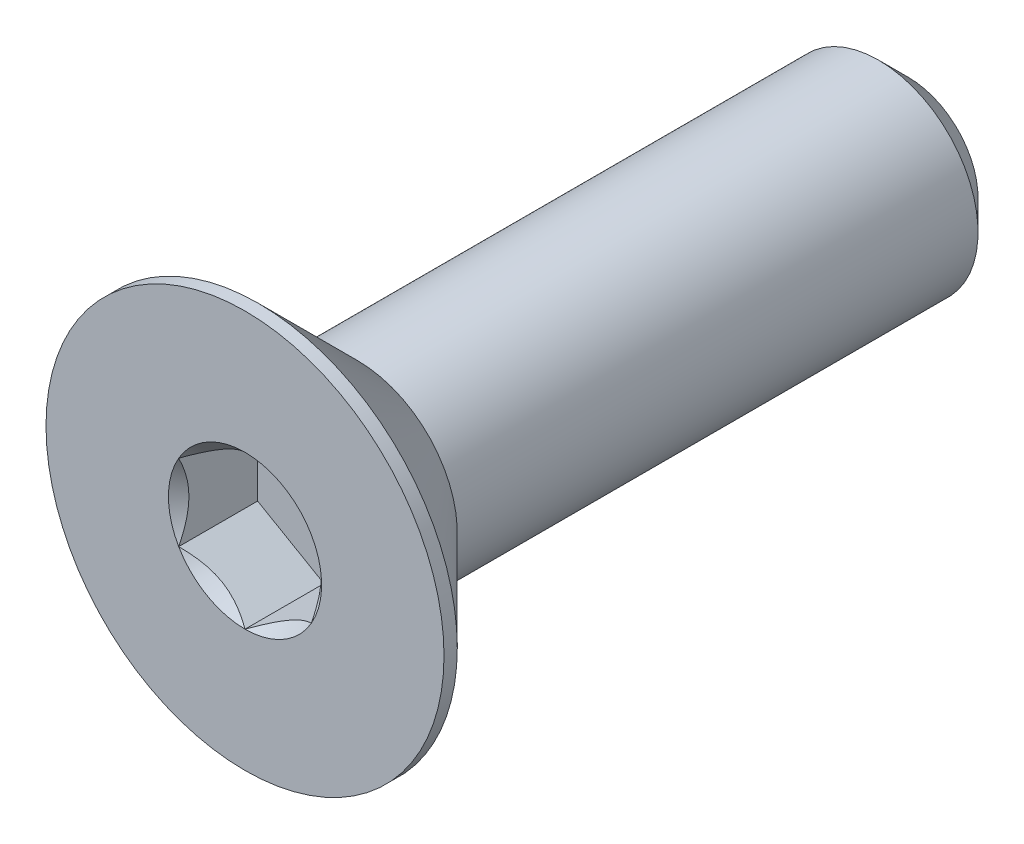
from build123d import *

# Parameters (mm, degrees)
SKETCH3_W          = 10
SKETCH3_H          = 1.5
CHAMFER1_SIZE      = 0.45
CUT_EXTRUDE1_DEPTH = 1.19


with BuildPart() as part:
    # Sketch3 → Revolve1 (revolve)
    with BuildSketch(Plane(origin=(0, 0, 0), x_dir=(0, 0, -1), z_dir=(1, 0, 0))):
        with Locations((0, 0.75)):
            Rectangle(SKETCH3_W, SKETCH3_H)
    revolve(axis=Axis((0, 0, -5), (0, 0, 1)))

    # Chamfer1
    chamfer1_edges = [part.edges().sort_by_distance(p)[0] for p in [
        (0, -1.5, -5),
    ]]
    chamfer(chamfer1_edges, length=CHAMFER1_SIZE)

    # Sketch6 → Revolve2 (revolve)
    with BuildSketch(Plane(origin=(0, 0, 0), x_dir=(0, 0, -1), z_dir=(1, 0, 0))):
        Polygon((-5, 3), (-4.8, 3), (-3.3, 1.5), (-3.3, 0), (-5, 0), align=None)
    revolve(axis=Axis((0, 0, -5), (0, 0, 1)))

    # Sketch8 → Cut-Extrude1 (cut)
    with BuildSketch(Plane.XY.offset(5)):
        Polygon((0, 1.154700538), (-1, 0.577350269), (-1, -0.577350269), (0, -1.154700538), (1, -0.577350269), (1, 0.577350269), align=None)
    extrude(amount=-CUT_EXTRUDE1_DEPTH, mode=Mode.SUBTRACT)

    # Cut-Extrude2 cone 1 section (through the dimple's axis) → Cut-Extrude2 (revolve, cut)
    with BuildSketch(Plane(origin=(0, 0, 5), x_dir=(0, -1, 0), z_dir=(1, 0, 0))):
        Polygon((0, 0), (1.154700538, 0), (0, 1.154700538), align=None)
    revolve(axis=Axis((0, 0, 5), (0, 0, -1)), mode=Mode.SUBTRACT)


solid = part.part
